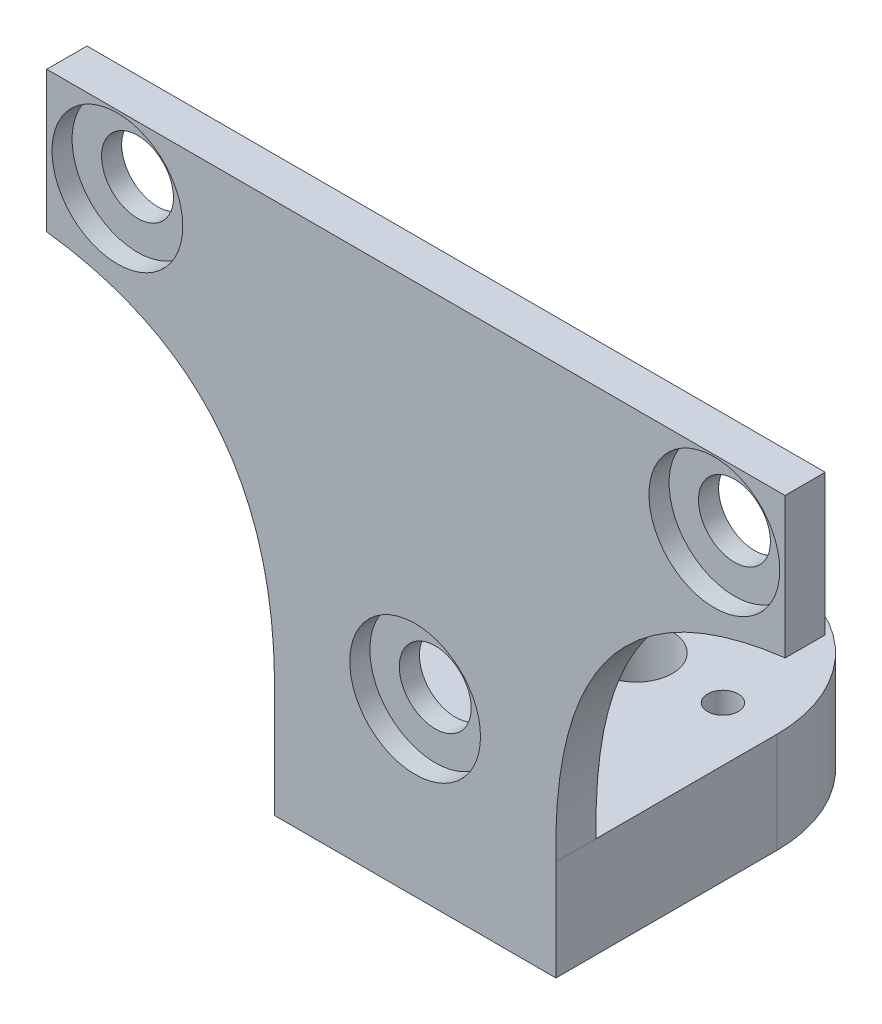
from build123d import *

# Parameters (mm, degrees)
ESQUISSE1_R             = 3.575
BOSS_EXTRU_1_DEPTH      = 4
ESQUISSE17_R            = 6.5
ENL_V_MAT_EXTRU_9_DEPTH = 2
ESQUISSE18_R            = 3.575
ESQUISSE18_R_2          = 1.525
BOSS_EXTRU_6_DEPTH      = 10


with BuildPart() as part:
    # Esquisse1 → Boss.-Extru.1 (new body)
    with BuildSketch(Plane.XY):
        with BuildLine():
            Line((0, 42.932447878), (0, 28.932447878))
            add(Edge.make_bspline(
                [(0, 28.932447878), (23.217449625, 26.022104371), (22.625, 0)],
                knots=[0, 0, 0, 1, 1, 1], degree=2))
            Line((22.625, 0), (36.625, 0))
            Line((36.625, 0), (50.625, 0))
            add(Edge.make_bspline(
                [(73.25, 28.932447878), (50.032550375, 26.022104371), (50.625, 0)],
                knots=[0, 0, 0, 1, 1, 1], degree=2))
            Line((73.25, 28.932447878), (73.4, 28.932447878))
            Line((73.4, 28.932447878), (73.4, 42.932447878))
            Line((73.4, 42.932447878), (0, 42.932447878))
        make_face()
        with Locations((7.025, 36.178525203)):
            Circle(ESQUISSE1_R, mode=Mode.SUBTRACT)
        with Locations((66.375, 36.245920154)):
            Circle(ESQUISSE1_R, mode=Mode.SUBTRACT)
        with Locations((36.625, 7.025)):
            Circle(ESQUISSE1_R, mode=Mode.SUBTRACT)
    extrude(amount=BOSS_EXTRU_1_DEPTH)

    # Esquisse17 → Enlèv. mat.-Extru.9 (cut)
    with BuildSketch(Plane.XY.offset(4)):
        with Locations((7.025, 36.178525203)):
            Circle(ESQUISSE17_R)
        with Locations((66.375, 36.245920154)):
            Circle(ESQUISSE17_R)
        with Locations((36.625, 7.025)):
            Circle(ESQUISSE17_R)
    extrude(amount=-ENL_V_MAT_EXTRU_9_DEPTH, mode=Mode.SUBTRACT)

    # Esquisse18 → Boss.-Extru.6 (add)
    with BuildSketch(Plane.XZ):
        with BuildLine():
            Line((22.625, -18), (22.625, 4))
            Line((22.625, 4), (50.625, 4))
            Line((50.625, 4), (50.625, -18))
            ThreePointArc((50.625, -18), (36.625, -32), (22.625, -18))
        make_face()
        with Locations((36.625, -18)):
            Circle(ESQUISSE18_R, mode=Mode.SUBTRACT)
        with Locations((28.025, -18)):
            Circle(ESQUISSE18_R_2, mode=Mode.SUBTRACT)
        with Locations((45.225, -18)):
            Circle(ESQUISSE18_R_2, mode=Mode.SUBTRACT)
    extrude(amount=BOSS_EXTRU_6_DEPTH)


solid = part.part
